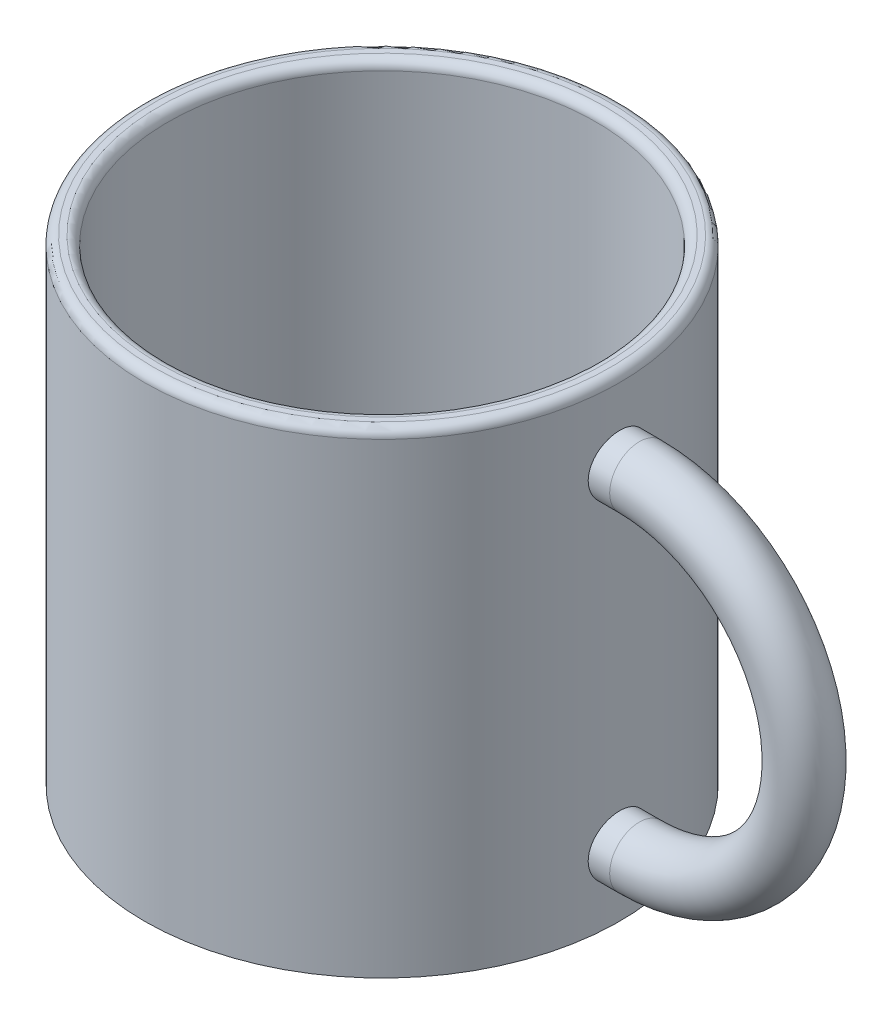
from build123d import *

# Parameters (mm, degrees)
SKETCH1_R          = 20
EXTRUDE1_DEPTH     = 40
SKETCH2_R          = 2.5
SKETCH4_R          = 18
CUT_EXTRUDE1_DEPTH = 38
FILLET1_R          = 0.75
FILLET2_R          = 0.75
SCALE1_SCALE       = 2.5
SCALE2_SCALE       = 1.2


with BuildPart() as part:
    # Sketch1 → Extrude1 (new body)
    with BuildSketch(Plane(origin=(0, 0, 0), x_dir=(1, 0, 0), z_dir=(0, 1, 0))):
        Circle(SKETCH1_R)
    extrude(amount=EXTRUDE1_DEPTH)

    # Sweep1: sweep along a path in Sketch3
    with BuildLine(Plane.XY) as sweep1_path:
        Line((0, 30.773001508), (21.65, 30.773001508))
        ThreePointArc((21.65, 30.773001508), (33.01, 19.413001508), (21.65, 8.053001508))
        Line((21.65, 8.053001508), (0, 8.053001508))
    # Sketch2 → Sweep1 (sweep)
    with BuildSketch(Plane(origin=(0, 0, 0), x_dir=(0, 0, -1), z_dir=(1, 0, 0))):
        with Locations((0, 33.273001508)):
            Circle(SKETCH2_R)
    sweep(path=sweep1_path.line)

    # Sketch4 → Cut-Extrude1 (cut)
    with BuildSketch(Plane(origin=(0, 40, 0), x_dir=(-1, 0, 0), z_dir=(0, 1, 0))):
        Circle(SKETCH4_R)
    extrude(amount=-CUT_EXTRUDE1_DEPTH, mode=Mode.SUBTRACT)

    # Fillet1
    fillet1_edges = [part.edges().sort_by_distance(p)[0] for p in [
        (18, 40, 0),
        (-20, 40, 0),
    ]]
    fillet(fillet1_edges, radius=FILLET1_R)

    # Fillet2
    fillet2_edges = [part.edges().sort_by_distance(p)[0] for p in [
        (18, 2, 0),
    ]]
    fillet(fillet2_edges, radius=FILLET2_R)


with BuildPart() as part_1:
    # Scale1: scaled about (2.200885097, 16.795438051, 2.029e-06)
    add(part.part.scale(SCALE1_SCALE).moved(Location((-3.301327645, -25.193157077, -3.043e-06))))


with BuildPart() as part_2:
    # Scale2: scaled about (2.200885096, 16.795438052, 2.029e-06)
    add(part_1.part.scale(SCALE2_SCALE).moved(Location((-0.440177019, -3.35908761, -4.06e-07))))


solid = part_2.part
